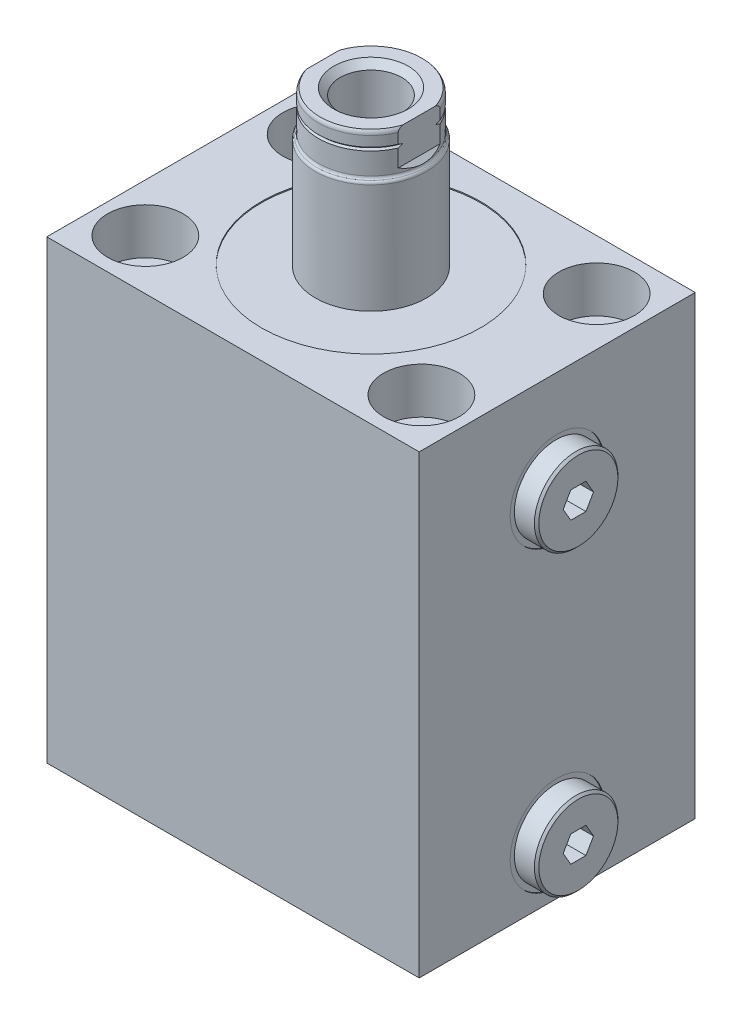
from build123d import *

# Parameters (mm, degrees)
SKETCH1_W                  = 85
SKETCH1_H                  = 63
EXTRUDE1_DEPTH             = 104
SKETCH2_R                  = 25
CUT_EXTRUDE1_DEPTH         = 0.254
CHAMFER1_SIZE              = 0.508
CUT_EXTRUDE2_DEPTH         = 5.9944
LPATTERN1_COUNT            = 2
LPATTERN1_PITCH            = 68
CHAMFER1_OF_LPATTERN1_SIZE = 0.508
SKETCH7_R                  = 0.889
LPATTERN2_COUNT            = 2
LPATTERN2_PITCH            = 31.5
CUT_EXTRUDE3_DEPTH         = 32.5
CUT_EXTRUDE3_DEPTH_BACK    = 32.5
HOLE1_D                    = 10.49
HOLE1_CBORE_D              = 17.247
HOLE1_CBORE_DEPTH          = 10.49


with BuildPart() as part:
    # Sketch1 → Extrude1 (new body)
    with BuildSketch(Plane(origin=(0, 0, 0), x_dir=(1, 0, 0), z_dir=(0, 1, 0))):
        Rectangle(SKETCH1_W, SKETCH1_H)
    extrude(amount=EXTRUDE1_DEPTH)

    # Sketch2 → Cut-Extrude1 (cut)
    with BuildSketch(Plane(origin=(0, 104, 0), x_dir=(1, 0, 0), z_dir=(0, 1, 0))):
        with Locations(Location((0, 0, 0), (0, 0, 270))):  # turned: the seam where the file's is
            Circle(SKETCH2_R)
    extrude(amount=-CUT_EXTRUDE1_DEPTH, mode=Mode.SUBTRACT)

    # Sketch3 → Cut-Revolve1 (revolve, cut)
    with BuildSketch(Plane.XY, mode=Mode.PRIVATE) as cut_revolve1_sk:
        Polygon((42.5, 81), (42.5, 70.256), (42.246, 70.256), (42.246, 74.3452), (41.5348, 75.0564), (26.752, 75.0564), (26.752, 81), align=None)
    cut_revolve1 = revolve(cut_revolve1_sk.sketch.rotate(Axis((-6.847979502, 81, 0), (1, 0, 0)), 270), axis=Axis((-6.847979502, 81, 0), (1, 0, 0)), mode=Mode.SUBTRACT)  # turned: the seam where the file's is

    # Sketch4 → Revolve1 (revolve)
    with BuildSketch(Plane.XY, mode=Mode.PRIVATE) as revolve1_sk:
        Polygon((30.308, 81), (30.308, 86.9182), (42.246, 86.9182), (42.246, 90.525), (47.326, 90.525), (47.326, 81), align=None)
    revolve1 = revolve(revolve1_sk.sketch.rotate(Axis((8.732572807, 81, 0), (1, 0, 0)), 90), axis=Axis((8.732572807, 81, 0), (1, 0, 0)))  # turned: the seam where the file's is

    # Chamfer1
    chamfer1_edges = [part.edges().sort_by_distance(p)[0] for p in [
        (47.326, 81, -9.525),
    ]]
    chamfer(chamfer1_edges, length=CHAMFER1_SIZE)

    # Sketch5 → Cut-Extrude2 (cut)
    with BuildSketch(Plane(origin=(47.326, 0, 0), x_dir=(0, 0, -1), z_dir=(1, 0, 0))):
        Polygon((1.730434227, 83.9972), (-1.730434227, 83.9972), (-3.460868454, 81), (-1.730434227, 78.0028), (1.730434227, 78.0028), (3.460868454, 81), align=None)
    cut_extrude2 = extrude(amount=-CUT_EXTRUDE2_DEPTH, mode=Mode.SUBTRACT)

    # LPattern1: Cut-Revolve1, Revolve1, Cut-Extrude2 ×2
    with Locations(*[(0, -i * LPATTERN1_PITCH, 0) for i in range(1, LPATTERN1_COUNT)]):
        add(cut_revolve1, mode=Mode.SUBTRACT)
        add(revolve1)
        add(cut_extrude2, mode=Mode.SUBTRACT)

    # Chamfer1 of LPattern1
    chamfer1_of_lpattern1_edges = [part.edges().sort_by_distance(p)[0] for p in [
        (47.326, 13, -9.525),
    ]]
    chamfer(chamfer1_of_lpattern1_edges, length=CHAMFER1_OF_LPATTERN1_SIZE)

    # Sketch6 → Cut-Revolve2 (revolve, cut)
    with BuildSketch(Plane.XY, mode=Mode.PRIVATE) as cut_revolve2_sk:
        Polygon((0, 0), (0, 14.895831126), (1.2446, 14.148), (1.2446, 4.9529), (1.7525, 4.445), (3.2512, 4.445), (3.2512, 1.448), (5.7025, 1.448), (5.7025, 0), align=None)
    cut_revolve2 = revolve(cut_revolve2_sk.sketch.rotate(Axis((0, 0, 0), (0, 1, 0)), 90), axis=Axis((0, 0, 0), (0, 1, 0)), mode=Mode.SUBTRACT)  # turned: the seam where the file's is

    # Sketch7 → Revolve3 (revolve)
    with BuildSketch(Plane.XY, mode=Mode.PRIVATE) as revolve3_sk:
        with Locations((4.814, 0.5844)):
            Circle(SKETCH7_R)
    revolve3 = revolve(revolve3_sk.sketch.rotate(Axis((0, 0, 0), (0, 1, 0)), 90), axis=Axis((0, 0, 0), (0, 1, 0)))  # turned: the seam where the file's is

    # LPattern2: Cut-Revolve2, Revolve3 ×2
    with Locations(*[(-i * LPATTERN2_PITCH, 0, 0) for i in range(1, LPATTERN2_COUNT)]):
        add(cut_revolve2, mode=Mode.SUBTRACT)
        add(revolve3)

    # Sketch8 → Revolve4 (revolve)
    with BuildSketch(Plane.XY, mode=Mode.PRIVATE) as revolve4_sk:
        with BuildLine():
            Line((12.6875, 103.746), (12.6875, 128.726091153))
            ThreePointArc((12.6875, 128.726091153), (12.596078295, 129.087987202), (12.34375, 129.363045577))
            ThreePointArc((12.34375, 129.363045577), (12.091421705, 129.638103951), (12, 130))
            Line((12, 130), (12, 138.0094))
            ThreePointArc((12, 138.0094), (11.905612002, 138.537401443), (11.634139733, 139))
            Line((11.634139733, 139), (0, 139))
            Line((0, 139), (0, 103.746))
            Line((0, 103.746), (12.6875, 103.746))
        make_face()
    revolve(revolve4_sk.sketch.rotate(Axis((0, 0, 0), (0, 1, 0)), 90), axis=Axis((0, 0, 0), (0, 1, 0)))  # turned: the seam where the file's is

    # Sketch10 → Cut-Revolve3 (revolve, cut)
    with BuildSketch(Plane.XY, mode=Mode.PRIVATE) as cut_revolve3_sk:
        Polygon((8.5, 139), (7.0105, 137.5105), (7.0105, 109.03), (0, 104.81766663), (0, 139), align=None)
    revolve(cut_revolve3_sk.sketch.rotate(Axis((0, 139, 0), (0, -1, 0)), 270), axis=Axis((0, 139, 0), (0, -1, 0)), mode=Mode.SUBTRACT)  # turned: the seam where the file's is

    # Sketch11 → Cut-Revolve4 (revolve, cut)
    with BuildSketch(Plane.XY, mode=Mode.PRIVATE) as cut_revolve4_sk:
        Polygon((12, 135.698), (11.619, 135.317), (12, 134.936), align=None)
    revolve(cut_revolve4_sk.sketch.rotate(Axis((0, 0, 0), (0, 1, 0)), 90), axis=Axis((0, 0, 0), (0, 1, 0)), mode=Mode.SUBTRACT)  # turned: the seam where the file's is

    # Sketch12 → Cut-Extrude3 (cut, two sides)
    with BuildSketch(Plane.XY) as cut_extrude3_sk:
        Polygon((11, 139), (11, 131), (12.6875, 129.3125), (12.6875, 139), align=None)
        Polygon((-12.6875, 139), (-11, 139), (-11, 131), (-12.6875, 129.3125), align=None)
    extrude(amount=CUT_EXTRUDE3_DEPTH, mode=Mode.SUBTRACT)
    extrude(cut_extrude3_sk.sketch, amount=-CUT_EXTRUDE3_DEPTH_BACK, mode=Mode.SUBTRACT)

    # Hole1 (through all)
    with Locations(Plane(origin=(0, 104, 0), x_dir=(-1, 0, 0), z_dir=(0, 1, 0))):
        with Locations((31.5, 20), (31.5, -20), (-31.5, -20), (-31.5, 20)):
            CounterBoreHole(HOLE1_D / 2, HOLE1_CBORE_D / 2, HOLE1_CBORE_DEPTH)


solid = part.part
